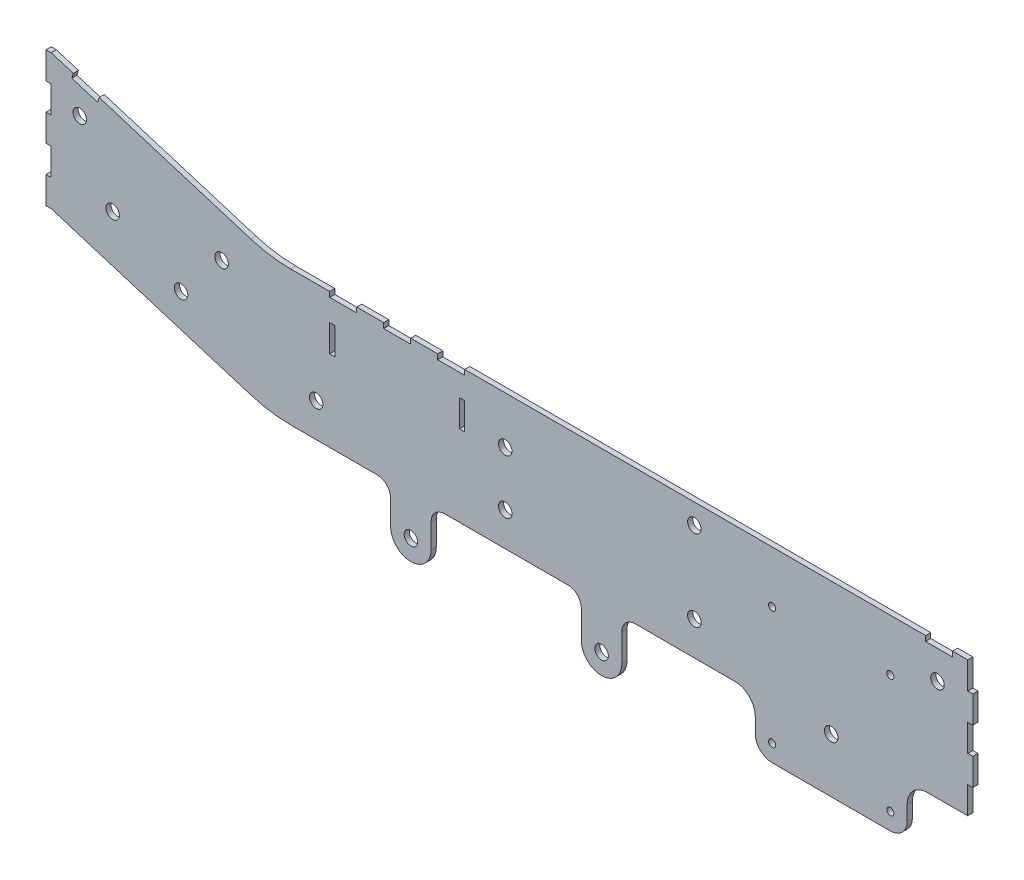
from build123d import *

# Parameters (mm, degrees)
SKETCH2_R                           = 6.35
BASE_DEPTH                          = 4.826
SKETCH3_W                           = 4.826
SKETCH3_H                           = 25.4
CENTER_SUPPORT_VERTICAL_HOLES_DEPTH = 5.826
SKETCH4_W                           = 4.826
SKETCH4_H                           = 25.4
CUT_EXTRUDE2_DEPTH                  = 9.652
SKETCH5_R                           = 3.3528
BOSS_EXTRUDE1_DEPTH                 = 4.826
SKETCH6_R                           = 3.3528
CUT_EXTRUDE3_DEPTH                  = 5.826
SKETCH7_W                           = 25.4
SKETCH7_H                           = 4.826
CUT_EXTRUDE4_DEPTH                  = 4.826


with BuildPart() as part:
    # Sketch2 → base (new body)
    with BuildSketch(Plane.XY):
        with BuildLine():
            Line((-214.699698696, -160.199792202), (-26.873942154, -218.069670807))
            ThreePointArc((-26.873942154, -218.069670807), (-8.387395977, -222.284374422), (10.520610491, -223.699792202))
            Line((10.520610491, -223.699792202), (91.809301303, -223.699792202))
            ThreePointArc((91.809301303, -223.699792202), (100.789557424, -227.419536081), (104.509301303, -236.399792202))
            Line((104.509301303, -236.399792202), (104.509301303, -259.444792203))
            ThreePointArc((104.509301303, -259.444792203), (123.559301303, -278.494792203), (142.609301303, -259.444792203))
            Line((142.609301303, -259.444792203), (142.609301303, -236.399792202))
            ThreePointArc((142.609301303, -236.399792202), (146.329045182, -227.419536081), (155.309301303, -223.699792202))
            Line((155.309301303, -223.699792202), (271.099301303, -223.699792202))
            ThreePointArc((271.099301303, -223.699792202), (280.079557424, -227.419536081), (283.799301303, -236.399792202))
            Line((283.799301303, -236.399792202), (283.799301303, -262.624792203))
            ThreePointArc((283.799301303, -262.624792203), (302.849301303, -281.674792203), (321.899301303, -262.624792203))
            Line((321.899301303, -262.624792203), (321.899301303, -236.399792202))
            ThreePointArc((321.899301303, -236.399792202), (325.619045182, -227.419536081), (334.599301303, -223.699792202))
            Line((334.599301303, -223.699792202), (476.201681216, -223.699792202))
            ThreePointArc((476.201681216, -223.699792202), (482.250146931, -225.232605336), (486.838586238, -229.461042202))
            ThreePointArc((486.838586238, -229.461042202), (518.749301303, -246.744792203), (550.660016368, -229.461042202))
            ThreePointArc((550.660016368, -229.461042202), (555.248455675, -225.232605336), (561.29692139, -223.699792202))
            Line((561.29692139, -223.699792202), (656.774301304, -223.699792202))
            Line((656.774301304, -223.699792202), (656.774301304, -198.299792202))
            Line((656.774301304, -198.299792202), (651.948301304, -198.299792202))
            Line((651.948301304, -198.299792202), (651.948301304, -172.899792202))
            Line((651.948301304, -172.899792202), (656.774301304, -172.899792202))
            Line((656.774301304, -172.899792202), (656.774301304, -147.499792202))
            Line((656.774301304, -147.499792202), (651.948301304, -147.499792202))
            Line((651.948301304, -147.499792202), (651.948301304, -122.099792202))
            Line((651.948301304, -122.099792202), (656.774301304, -122.099792202))
            Line((656.774301304, -122.099792202), (656.774301304, -96.699792202))
            Line((656.774301304, -96.699792202), (174.174301304, -96.699792202))
            Line((174.174301304, -96.699792202), (174.174301304, -101.525792202))
            Line((174.174301304, -101.525792202), (148.774301304, -101.525792202))
            Line((148.774301304, -101.525792202), (148.774301304, -96.699792202))
            Line((148.774301304, -96.699792202), (123.374301304, -96.699792202))
            Line((123.374301304, -96.699792202), (123.374301304, -101.525792202))
            Line((123.374301304, -101.525792202), (97.974301304, -101.525792202))
            Line((97.974301304, -101.525792202), (97.974301304, -96.699792202))
            Line((97.974301304, -96.699792202), (72.574301304, -96.699792202))
            Line((72.574301304, -96.699792202), (72.574301304, -101.525792202))
            Line((72.574301304, -101.525792202), (47.174301304, -101.525792202))
            Line((47.174301304, -101.525792202), (47.174301304, -96.699792202))
            Line((47.174301304, -96.699792202), (10.520610491, -96.699792202))
            ThreePointArc((10.520610491, -96.699792202), (-8.387395977, -95.284374422), (-26.873942154, -91.069670807))
            Line((-26.873942154, -91.069670807), (-169.556754254, -47.108516771))
            Line((-169.556754254, -47.108516771), (-170.977747254, -51.720572158))
            Line((-170.977747254, -51.720572158), (-195.251722975, -44.241661629))
            Line((-195.251722975, -44.241661629), (-193.830729974, -39.629606242))
            Line((-193.830729974, -39.629606242), (-214.699698696, -33.199792202))
            Line((-214.699698696, -33.199792202), (-219.525698696, -33.199792202))
            Line((-219.525698696, -33.199792202), (-219.525698696, -58.599792202))
            Line((-219.525698696, -58.599792202), (-214.699698696, -58.599792202))
            Line((-214.699698696, -58.599792202), (-214.699698696, -83.999792202))
            Line((-214.699698696, -83.999792202), (-219.525698696, -83.999792202))
            Line((-219.525698696, -83.999792202), (-219.525698696, -109.399792202))
            Line((-219.525698696, -109.399792202), (-214.699698696, -109.399792202))
            Line((-214.699698696, -109.399792202), (-214.699698696, -134.799792202))
            Line((-214.699698696, -134.799792202), (-219.525698696, -134.799792202))
            Line((-219.525698696, -134.799792202), (-219.525698696, -160.199792202))
            Line((-219.525698696, -160.199792202), (-214.699698696, -160.199792202))
        make_face()
        with Locations((390.074301304, -191.949792202)):
            Circle(SKETCH2_R, mode=Mode.SUBTRACT)
        with Locations((390.074301304, -115.749792202)):
            Circle(SKETCH2_R, mode=Mode.SUBTRACT)
        with Locations((518.749301303, -221.344792203)):
            Circle(SKETCH2_R, mode=Mode.SUBTRACT)
        with Locations((618.674301304, -128.449792202)):
            Circle(SKETCH2_R, mode=Mode.SUBTRACT)
        with Locations((302.849301303, -262.624792203)):
            Circle(SKETCH2_R, mode=Mode.SUBTRACT)
        with Locations((212.274301304, -191.949792202)):
            Circle(SKETCH2_R, mode=Mode.SUBTRACT)
        with Locations((212.274301304, -141.149792202)):
            Circle(SKETCH2_R, mode=Mode.SUBTRACT)
        with Locations((123.559301303, -259.444792203)):
            Circle(SKETCH2_R, mode=Mode.SUBTRACT)
        with Locations((34.474301304, -191.949792202)):
            Circle(SKETCH2_R, mode=Mode.SUBTRACT)
        with Locations((-92.525698696, -166.549792202)):
            Circle(SKETCH2_R, mode=Mode.SUBTRACT)
        with Locations((-156.850698697, -133.724792203)):
            Circle(SKETCH2_R, mode=Mode.SUBTRACT)
        with Locations((-54.425698696, -122.099792202)):
            Circle(SKETCH2_R, mode=Mode.SUBTRACT)
        with Locations((-187.775698696, -71.299792202)):
            Circle(SKETCH2_R, mode=Mode.SUBTRACT)
    extrude(amount=BASE_DEPTH)

    # Sketch3 → center support vertical holes (cut, through all)
    with BuildSketch(Plane.XY.offset(4.826)):
        with Locations((171.761301304, -134.799792202)):
            Rectangle(SKETCH3_W, SKETCH3_H)
        with Locations((49.587301304, -134.799792202)):
            Rectangle(SKETCH3_W, SKETCH3_H)
    extrude(amount=-CENTER_SUPPORT_VERTICAL_HOLES_DEPTH, mode=Mode.SUBTRACT)

    # Sketch4 → Cut-Extrude2 (cut)
    with BuildSketch(Plane(origin=(656.774301304, 0, 0), x_dir=(0, 0, -1), z_dir=(1, 0, 0))):
        with Locations((-2.413, -109.399792202)):
            Rectangle(SKETCH4_W, SKETCH4_H)
        with Locations((-2.413, -160.199792202)):
            Rectangle(SKETCH4_W, SKETCH4_H)
        with Locations((-2.413, -210.999792202)):
            Rectangle(SKETCH4_W, SKETCH4_H)
    extrude(amount=-CUT_EXTRUDE2_DEPTH, mode=Mode.SUBTRACT)

    # Sketch5 → Boss-Extrude1 (add, through all)
    with BuildSketch(Plane.XY):
        with BuildLine():
            ThreePointArc((447.337201303, -256.561892203), (451.986881152, -267.787212355), (463.212201303, -272.436892203))
            Line((463.212201303, -272.436892203), (574.337201303, -272.436892203))
            ThreePointArc((574.337201303, -272.436892203), (585.562521454, -267.787212355), (590.212201303, -256.561892203))
            Line((590.212201303, -256.561892203), (590.212201303, -242.749792202))
            ThreePointArc((590.212201303, -242.749792202), (595.791817122, -229.279408021), (609.262201303, -223.699792202))
            Line((609.262201303, -223.699792202), (582.274701303, -223.699792202))
            Line((582.274701303, -223.699792202), (582.274701303, -263.705642203))
            ThreePointArc((582.274701303, -263.705642203), (582.042217311, -264.266908211), (581.480951303, -264.499392203))
            Line((581.480951303, -264.499392203), (456.068451303, -264.499392203))
            ThreePointArc((456.068451303, -264.499392203), (455.507185296, -264.266908211), (455.274701303, -263.705642203))
            Line((455.274701303, -263.705642203), (455.274701303, -223.699792202))
            Line((455.274701303, -223.699792202), (428.287201303, -223.699792202))
            ThreePointArc((428.287201303, -223.699792202), (441.757585485, -229.279408021), (447.337201303, -242.749792202))
            Line((447.337201303, -242.749792202), (447.337201303, -256.561892203))
        make_face()
        with BuildLine():
            Line((476.201681216, -223.699792202), (455.274701303, -223.699792202))
            Line((455.274701303, -223.699792202), (455.274701303, -263.705642203))
            ThreePointArc((455.274701303, -263.705642203), (455.507185296, -264.266908211), (456.068451303, -264.499392203))
            Line((456.068451303, -264.499392203), (581.480951303, -264.499392203))
            ThreePointArc((581.480951303, -264.499392203), (582.042217311, -264.266908211), (582.274701303, -263.705642203))
            Line((582.274701303, -263.705642203), (582.274701303, -223.699792202))
            Line((582.274701303, -223.699792202), (561.29692139, -223.699792202))
            ThreePointArc((561.29692139, -223.699792202), (561.2383345, -223.699927338), (561.179748857, -223.700332741))
            ThreePointArc((561.179748857, -223.700332741), (558.402047851, -225.427930059), (555.13360811, -225.295578164))
            ThreePointArc((555.13360811, -225.295578164), (552.64246552, -227.105148928), (550.660016368, -229.461042202))
            ThreePointArc((550.660016368, -229.461042202), (518.749301303, -246.744792203), (486.838586238, -229.461042202))
            ThreePointArc((486.838586238, -229.461042202), (484.864337354, -227.112791145), (482.384586489, -225.306475188))
            ThreePointArc((482.384586489, -225.306475188), (479.131749478, -225.423788448), (476.370155751, -223.700909719))
            ThreePointArc((476.370155751, -223.700909719), (476.285920337, -223.700071584), (476.201681216, -223.699792202))
        make_face()
        with Locations((463.212201303, -256.561892203)):
            Circle(SKETCH5_R, mode=Mode.SUBTRACT)
        with Locations((574.337201303, -256.561892203)):
            Circle(SKETCH5_R, mode=Mode.SUBTRACT)
        with BuildLine():
            ThreePointArc((486.129056336, -220.049392203), (478.617074751, -214.839552456), (476.370155751, -223.700909719))
            ThreePointArc((476.370155751, -223.700909719), (479.47726765, -224.129481142), (482.384586489, -225.306475188))
            ThreePointArc((482.384586489, -225.306475188), (485.097242667, -223.276541717), (486.129056336, -220.049392203))
        make_face()
        with BuildLine():
            ThreePointArc((482.384586489, -225.306475188), (479.47726765, -224.129481142), (476.370155751, -223.700909719))
            ThreePointArc((476.370155751, -223.700909719), (479.131749478, -225.423788448), (482.384586489, -225.306475188))
        make_face()
        with BuildLine():
            ThreePointArc((555.13360811, -225.295578164), (558.402047851, -225.427930059), (561.179748857, -223.700332741))
            ThreePointArc((561.179748857, -223.700332741), (558.056963443, -224.120025409), (555.13360811, -225.295578164))
        make_face()
        with BuildLine():
            ThreePointArc((555.13360811, -225.295578164), (558.056963443, -224.120025409), (561.179748857, -223.700332741))
            ThreePointArc((561.179748857, -223.700332741), (562.192920014, -221.998415637), (562.54554627, -220.049392203))
            ThreePointArc((562.54554627, -220.049392203), (553.769273114, -215.509037195), (555.13360811, -225.295578164))
        make_face()
    extrude(amount=BOSS_EXTRUDE1_DEPTH)

    # Sketch6 → Cut-Extrude3 (cut, through all)
    with BuildSketch(Plane.XY.offset(4.826)):
        with Locations((463.186801303, -145.436892203)):
            Circle(SKETCH6_R)
        with Locations((574.311801303, -145.436892203)):
            Circle(SKETCH6_R)
    extrude(amount=-CUT_EXTRUDE3_DEPTH, mode=Mode.SUBTRACT)

    # Sketch7 → Cut-Extrude4 (cut)
    with BuildSketch(Plane(origin=(0, -96.699792202, 0), x_dir=(1, 0, 0), z_dir=(0, 1, 0))):
        with Locations((620.198301304, -2.413)):
            Rectangle(SKETCH7_W, SKETCH7_H)
    extrude(amount=-CUT_EXTRUDE4_DEPTH, mode=Mode.SUBTRACT)


solid = part.part
